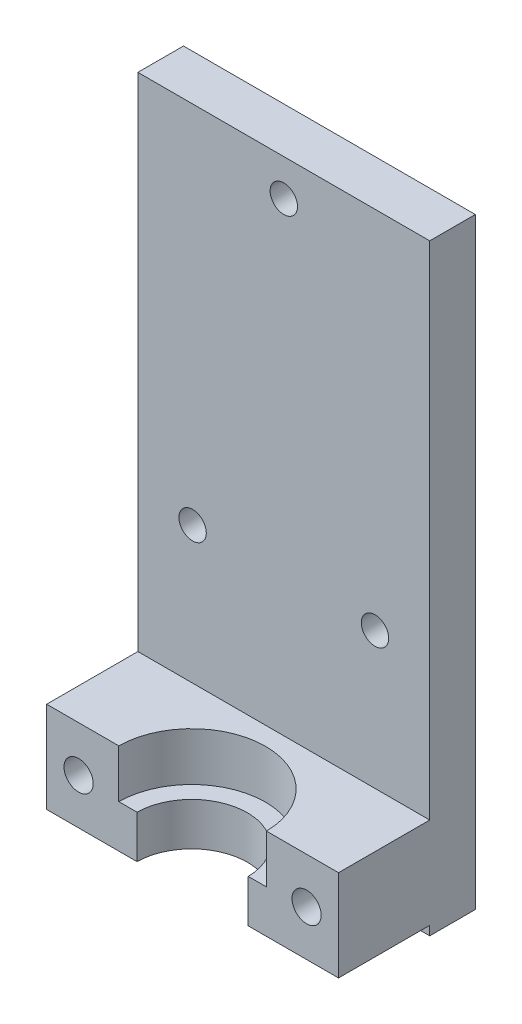
from build123d import *

# Parameters (mm, degrees)
SKETCH1_W           = 32
SKETCH1_H           = 66
SKETCH1_R           = 1.5
BOSS_EXTRUDE1_DEPTH = 25
SKETCH3_W           = 20
SKETCH3_H           = 55
SKETCH3_H_2         = 1
CUT_EXTRUDE1_DEPTH  = 33
SKETCH4_R           = 6.1
CUT_EXTRUDE6_DEPTH  = 12
SKETCH5_R           = 8.1
CUT_EXTRUDE7_DEPTH  = 5.3
SKETCH7_R           = 1.6
CUT_EXTRUDE8_DEPTH  = 26
CUT_EXTRUDE9_DEPTH  = 10
SKETCH10_W          = 32
SKETCH10_H          = 10
CUT_EXTRUDE10_DEPTH = 10


with BuildPart() as part:
    # Sketch1 → Boss-Extrude1 (new body)
    with BuildSketch(Plane.XY):
        with Locations((16, -33)):
            Rectangle(SKETCH1_W, SKETCH1_H)
        with Locations((16, -4)):
            Circle(SKETCH1_R, mode=Mode.SUBTRACT)
        with Locations((6, -40)):
            Circle(SKETCH1_R, mode=Mode.SUBTRACT)
        with Locations((26, -40)):
            Circle(SKETCH1_R, mode=Mode.SUBTRACT)
    extrude(amount=BOSS_EXTRUDE1_DEPTH)

    # Sketch3 → Cut-Extrude1 (cut, through all)
    with BuildSketch(Plane.ZY):
        with Locations((15, -27.5)):
            Rectangle(SKETCH3_W, SKETCH3_H)
        with Locations((15, -65.5)):
            Rectangle(SKETCH3_W, SKETCH3_H_2)
    extrude(amount=-CUT_EXTRUDE1_DEPTH, mode=Mode.SUBTRACT)

    # Sketch4 → Cut-Extrude6 (cut, through all)
    with BuildSketch(Plane(origin=(0, -55, 0), x_dir=(1, 0, 0), z_dir=(0, 1, 0))):
        with Locations((15.999687497, -15.1)):
            Circle(SKETCH4_R)
    extrude(amount=-CUT_EXTRUDE6_DEPTH, mode=Mode.SUBTRACT)

    # Sketch5 → Cut-Extrude7 (cut)
    with BuildSketch(Plane(origin=(0, -55, 0), x_dir=(1, 0, 0), z_dir=(0, 1, 0))):
        with Locations((15.999687497, -15.1)):
            Circle(SKETCH5_R)
    extrude(amount=-CUT_EXTRUDE7_DEPTH, mode=Mode.SUBTRACT)

    # Sketch7 → Cut-Extrude8 (cut, through all)
    with BuildSketch(Plane.XY.offset(25)):
        with Locations((3.5, -60)):
            Circle(SKETCH7_R)
        with Locations((28.5, -60)):
            Circle(SKETCH7_R)
    extrude(amount=-CUT_EXTRUDE8_DEPTH, mode=Mode.SUBTRACT)

    # Sketch9 → Cut-Extrude9 (cut)
    with BuildSketch(Plane(origin=(0, 0, 0), x_dir=(-1, 0, 0), z_dir=(0, 0, -1))):
        Polygon((-27.219059817, -57.232023799), (-30.256667615, -57.50668516), (-31.537607798, -60.274661361), (-29.780940183, -62.767976201), (-26.743332385, -62.49331484), (-25.462392202, -59.725338639), align=None)
        Polygon((-4.846024949, -57.263082603), (-6.543252468, -59.797233102), (-5.197227519, -62.534150498), (-2.153975051, -62.736917397), (-0.456747532, -60.202766898), (-1.802772481, -57.465849502), align=None)
    extrude(amount=-CUT_EXTRUDE9_DEPTH, mode=Mode.SUBTRACT)

    # Sketch10 → Cut-Extrude10 (cut)
    with BuildSketch(Plane.XY.offset(25)):
        with Locations((16, -60)):
            Rectangle(SKETCH10_W, SKETCH10_H)
    extrude(amount=-CUT_EXTRUDE10_DEPTH, mode=Mode.SUBTRACT)


solid = part.part
